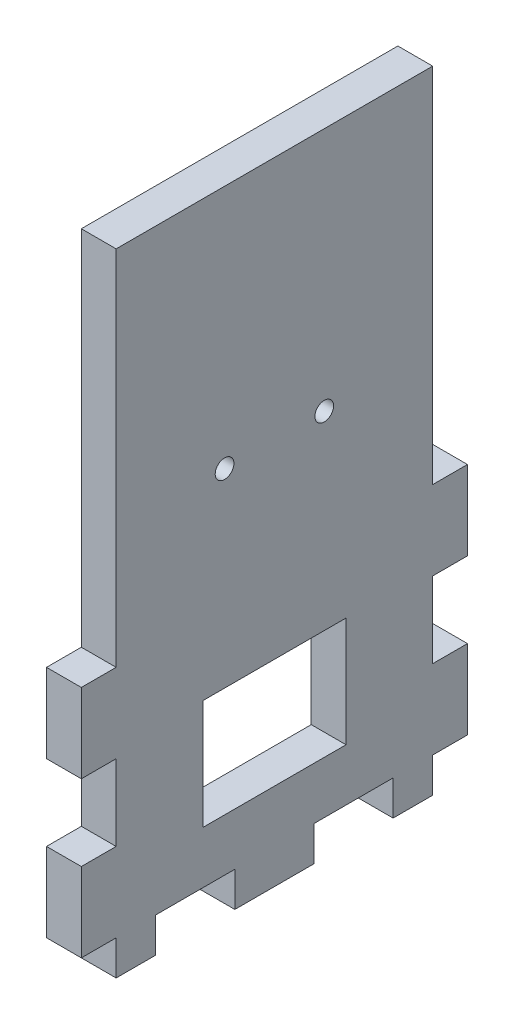
from build123d import *

# Parameters (mm, degrees)
SKETCH1_W              = 273.05
SKETCH1_H              = 139.7
BOSS_EXTRUDE1_DEPTH    = 5.588
SKETCH2_W              = 273.05
SKETCH2_H              = 139.7
SKETCH2_W_2            = 261.874
SKETCH2_H_2            = 128.524
BOSS_EXTRUDE2_DEPTH    = 298.45
SKETCH3_W              = 6.35
SKETCH3_H              = 16.933333333
SKETCH3_H_2            = 16.933333334
DOOR_SLOT_DEPTH        = 12.7
DOOR_GUIDE_HOLES_REACH = 361.255
SKETCH4_W              = 6.35
SKETCH4_H              = 15.875
LEVER_HOLES_W          = 9.652
LEVER_HOLES_H          = 6.35
LEVER_HOLES_W_2        = 6.35
CUT_EXTRUDE1_DEPTH     = 362.378293578
CUT_EXTRUDE3_REACH     = 416.577
SKETCH8_R              = 3.175
SKETCH16_W             = 327.238778096
SKETCH16_H             = 314.471565403
CUT_EXTRUDE10_DEPTH    = 362.378293578
LEFT_RIGHT_W           = 6.35
LEFT_RIGHT_H           = 5.588
LEFT_RIGHT_W_2         = 12.7
LEFT_RIGHT_H_2         = 12.66825
CUT_EXTRUDE11_DEPTH    = 415.577411883
SKETCH17_R             = 1.5
SKETCH17_W             = 23
SKETCH17_H             = 17.61800007
CUT_EXTRUDE12_DEPTH    = 313.00857951
CUT_EXTRUDE13_DEPTH    = 313.00857951


with BuildPart() as part:
    # Sketch1 → Boss-Extrude1 (new body)
    with BuildSketch(Plane(origin=(0, 0, 0), x_dir=(1, 0, 0), z_dir=(0, 1, 0))):
        Rectangle(SKETCH1_W, SKETCH1_H)
    extrude(amount=BOSS_EXTRUDE1_DEPTH)

    # Sketch2 → Boss-Extrude2 (add)
    with BuildSketch(Plane(origin=(0, 5.588, 0), x_dir=(1, 0, 0), z_dir=(0, 1, 0))):
        Rectangle(SKETCH2_W, SKETCH2_H)
        Rectangle(SKETCH2_W_2, SKETCH2_H_2, mode=Mode.SUBTRACT)
    extrude(amount=BOSS_EXTRUDE2_DEPTH)

    # Sketch3 → Door Slot (cut)
    with BuildSketch(Plane.XY.offset(69.85)):
        with BuildLine():
            Line((-29.337, 282.448), (-29.337, 5.588))
            Line((-29.337, 5.588), (-22.733, 5.588))
            Line((-22.733, 5.588), (-22.733, 291.592))
            Line((-22.733, 291.592), (-42.291, 291.592))
            Line((-42.291, 291.592), (-42.291, 284.988))
            Line((-42.291, 284.988), (-31.877, 284.988))
            ThreePointArc((-31.877, 284.988), (-30.080948776, 284.244051224), (-29.337, 282.448))
        make_face()
        with Locations((-13.208, 80.433333334)):
            Rectangle(SKETCH3_W, SKETCH3_H)
        with Locations((-13.208, 50.8)):
            Rectangle(SKETCH3_W, SKETCH3_H_2)
        with Locations((-13.208, 21.166666667)):
            Rectangle(SKETCH3_W, SKETCH3_H)
    extrude(amount=-DOOR_SLOT_DEPTH, mode=Mode.SUBTRACT)

    # Sketch4 → Door Guide Holes (cut, up to next)
    with BuildSketch(Plane.XY.offset(-64.262), mode=Mode.PRIVATE) as door_guide_holes_sk1:
        with Locations((-45.466, 283.4005)):
            Rectangle(SKETCH4_W, SKETCH4_H)
    door_guide_holes_tool1 = extrude(door_guide_holes_sk1.sketch, amount=-DOOR_GUIDE_HOLES_REACH, mode=Mode.PRIVATE) & part.part
    # Sketch4 → Door Guide Holes (cut, up to next)
    with BuildSketch(Plane.XY.offset(-64.262), mode=Mode.PRIVATE) as door_guide_holes_sk2:
        with Locations((-45.466, 254.8255)):
            Rectangle(SKETCH4_W, SKETCH4_H)
    door_guide_holes_tool2 = extrude(door_guide_holes_sk2.sketch, amount=-DOOR_GUIDE_HOLES_REACH, mode=Mode.PRIVATE) & part.part
    # Sketch4 → Door Guide Holes (cut, up to next)
    with BuildSketch(Plane.XY.offset(-64.262), mode=Mode.PRIVATE) as door_guide_holes_sk3:
        with Locations((-45.466, 226.2505)):
            Rectangle(SKETCH4_W, SKETCH4_H)
    door_guide_holes_tool3 = extrude(door_guide_holes_sk3.sketch, amount=-DOOR_GUIDE_HOLES_REACH, mode=Mode.PRIVATE) & part.part
    # Sketch4 → Door Guide Holes (cut, up to next)
    with BuildSketch(Plane.XY.offset(-64.262), mode=Mode.PRIVATE) as door_guide_holes_sk4:
        with Locations((-45.466, 197.6755)):
            Rectangle(SKETCH4_W, SKETCH4_H)
    door_guide_holes_tool4 = extrude(door_guide_holes_sk4.sketch, amount=-DOOR_GUIDE_HOLES_REACH, mode=Mode.PRIVATE) & part.part
    # Sketch4 → Door Guide Holes (cut, up to next)
    with BuildSketch(Plane.XY.offset(-64.262), mode=Mode.PRIVATE) as door_guide_holes_sk5:
        with Locations((-45.466, 169.1005)):
            Rectangle(SKETCH4_W, SKETCH4_H)
    door_guide_holes_tool5 = extrude(door_guide_holes_sk5.sketch, amount=-DOOR_GUIDE_HOLES_REACH, mode=Mode.PRIVATE) & part.part
    # Sketch4 → Door Guide Holes (cut, up to next)
    with BuildSketch(Plane.XY.offset(-64.262), mode=Mode.PRIVATE) as door_guide_holes_sk6:
        with Locations((-45.466, 140.5255)):
            Rectangle(SKETCH4_W, SKETCH4_H)
    door_guide_holes_tool6 = extrude(door_guide_holes_sk6.sketch, amount=-DOOR_GUIDE_HOLES_REACH, mode=Mode.PRIVATE) & part.part
    # Sketch4 → Door Guide Holes (cut, up to next)
    with BuildSketch(Plane.XY.offset(-64.262), mode=Mode.PRIVATE) as door_guide_holes_sk7:
        with Locations((-45.466, 111.9505)):
            Rectangle(SKETCH4_W, SKETCH4_H)
    door_guide_holes_tool7 = extrude(door_guide_holes_sk7.sketch, amount=-DOOR_GUIDE_HOLES_REACH, mode=Mode.PRIVATE) & part.part
    # Sketch4 → Door Guide Holes (cut, up to next)
    with BuildSketch(Plane.XY.offset(-64.262), mode=Mode.PRIVATE) as door_guide_holes_sk8:
        with Locations((-45.466, 83.3755)):
            Rectangle(SKETCH4_W, SKETCH4_H)
    door_guide_holes_tool8 = extrude(door_guide_holes_sk8.sketch, amount=-DOOR_GUIDE_HOLES_REACH, mode=Mode.PRIVATE) & part.part
    # Sketch4 → Door Guide Holes (cut, up to next)
    with BuildSketch(Plane.XY.offset(-64.262), mode=Mode.PRIVATE) as door_guide_holes_sk9:
        with Locations((-45.466, 54.8005)):
            Rectangle(SKETCH4_W, SKETCH4_H)
    door_guide_holes_tool9 = extrude(door_guide_holes_sk9.sketch, amount=-DOOR_GUIDE_HOLES_REACH, mode=Mode.PRIVATE) & part.part
    # Sketch4 → Door Guide Holes (cut, up to next)
    with BuildSketch(Plane.XY.offset(-64.262), mode=Mode.PRIVATE) as door_guide_holes_sk10:
        with Locations((-45.466, 26.2255)):
            Rectangle(SKETCH4_W, SKETCH4_H)
    door_guide_holes_tool10 = extrude(door_guide_holes_sk10.sketch, amount=-DOOR_GUIDE_HOLES_REACH, mode=Mode.PRIVATE) & part.part
    door_guide_holes_1 = door_guide_holes_tool1.solids().sort_by_distance((-45.466, 283.4005, -64.262))[0]
    add(door_guide_holes_1, mode=Mode.SUBTRACT)
    door_guide_holes_2 = door_guide_holes_tool2.solids().sort_by_distance((-45.466, 254.8255, -64.262))[0]
    add(door_guide_holes_2, mode=Mode.SUBTRACT)
    door_guide_holes_3 = door_guide_holes_tool3.solids().sort_by_distance((-45.466, 226.2505, -64.262))[0]
    add(door_guide_holes_3, mode=Mode.SUBTRACT)
    door_guide_holes_4 = door_guide_holes_tool4.solids().sort_by_distance((-45.466, 197.6755, -64.262))[0]
    add(door_guide_holes_4, mode=Mode.SUBTRACT)
    door_guide_holes_5 = door_guide_holes_tool5.solids().sort_by_distance((-45.466, 169.1005, -64.262))[0]
    add(door_guide_holes_5, mode=Mode.SUBTRACT)
    door_guide_holes_6 = door_guide_holes_tool6.solids().sort_by_distance((-45.466, 140.5255, -64.262))[0]
    add(door_guide_holes_6, mode=Mode.SUBTRACT)
    door_guide_holes_7 = door_guide_holes_tool7.solids().sort_by_distance((-45.466, 111.9505, -64.262))[0]
    add(door_guide_holes_7, mode=Mode.SUBTRACT)
    door_guide_holes_8 = door_guide_holes_tool8.solids().sort_by_distance((-45.466, 83.3755, -64.262))[0]
    add(door_guide_holes_8, mode=Mode.SUBTRACT)
    door_guide_holes_9 = door_guide_holes_tool9.solids().sort_by_distance((-45.466, 54.8005, -64.262))[0]
    add(door_guide_holes_9, mode=Mode.SUBTRACT)
    door_guide_holes_10 = door_guide_holes_tool10.solids().sort_by_distance((-45.466, 26.2255, -64.262))[0]
    add(door_guide_holes_10, mode=Mode.SUBTRACT)
    door_guide_holes = door_guide_holes_1 + door_guide_holes_2 + door_guide_holes_3 + door_guide_holes_4 + door_guide_holes_5 + door_guide_holes_6 + door_guide_holes_7 + door_guide_holes_8 + door_guide_holes_9 + door_guide_holes_10  # Door Guide Holes as one shape, for the pattern or mirror that repeats it

    # Mirror1: Door Guide Holes across plane
    add(door_guide_holes.mirror(Plane.ZY.offset(32.512)), mode=Mode.SUBTRACT)

    # Lever Holes → Cut-Extrude1 (cut, through all)
    with BuildSketch(Plane.XY.offset(69.85)):
        with Locations((54.102, 28.575)):
            Rectangle(LEVER_HOLES_W, LEVER_HOLES_H)
        with Locations((39.3065, 15.875)):
            Rectangle(LEVER_HOLES_W_2, LEVER_HOLES_H)
        with Locations((68.8975, 15.875)):
            Rectangle(LEVER_HOLES_W_2, LEVER_HOLES_H)
    extrude(amount=-CUT_EXTRUDE1_DEPTH, mode=Mode.SUBTRACT)

    # Sketch8 → Cut-Extrude3 (cut, up to next)
    with BuildSketch(Plane.ZY.offset(136.525), mode=Mode.PRIVATE) as cut_extrude3_sk1:
        with Locations((0, 19.05)):
            Circle(SKETCH8_R)
    cut_extrude3_tool1 = extrude(cut_extrude3_sk1.sketch, amount=-CUT_EXTRUDE3_REACH, mode=Mode.PRIVATE) & part.part
    add(cut_extrude3_tool1.solids().sort_by_distance((-136.525, 19.05, 0))[0], mode=Mode.SUBTRACT)

    # Sketch16 → Cut-Extrude10 (cut, through all)
    with BuildSketch(Plane.XY.offset(69.85)):
        with Locations((-32.682389048, 146.802217299)):
            Rectangle(SKETCH16_W, SKETCH16_H)
    extrude(amount=-CUT_EXTRUDE10_DEPTH, mode=Mode.SUBTRACT)

    # Left/Right → Cut-Extrude11 (cut, through all)
    with BuildSketch(Plane.ZY.offset(136.525)):
        with Locations((60.325, 2.794)):
            Rectangle(LEFT_RIGHT_W, LEFT_RIGHT_H)
        with Locations((38.1, 2.794)):
            Rectangle(LEFT_RIGHT_W_2, LEFT_RIGHT_H)
        with Locations((66.675, 19.002375)):
            Rectangle(LEFT_RIGHT_W, LEFT_RIGHT_H_2)
        with Locations((12.7, 2.794)):
            Rectangle(LEFT_RIGHT_W_2, LEFT_RIGHT_H)
        with Locations((66.675, 44.338875)):
            Rectangle(LEFT_RIGHT_W, LEFT_RIGHT_H_2)
        with Locations((-12.7, 2.794)):
            Rectangle(LEFT_RIGHT_W_2, LEFT_RIGHT_H)
        with Locations((66.675, 69.675375)):
            Rectangle(LEFT_RIGHT_W, LEFT_RIGHT_H_2)
        with Locations((-38.1, 2.794)):
            Rectangle(LEFT_RIGHT_W_2, LEFT_RIGHT_H)
        with Locations((66.675, 95.011875)):
            Rectangle(LEFT_RIGHT_W, LEFT_RIGHT_H_2)
        with Locations((-60.325, 2.794)):
            Rectangle(LEFT_RIGHT_W, LEFT_RIGHT_H)
        with Locations((66.675, 120.348375)):
            Rectangle(LEFT_RIGHT_W, LEFT_RIGHT_H_2)
        with Locations((-66.675, 19.002375)):
            Rectangle(LEFT_RIGHT_W, LEFT_RIGHT_H_2)
        with Locations((66.675, 145.684875)):
            Rectangle(LEFT_RIGHT_W, LEFT_RIGHT_H_2)
        with Locations((-66.675, 44.338875)):
            Rectangle(LEFT_RIGHT_W, LEFT_RIGHT_H_2)
        with Locations((66.675, 171.021375)):
            Rectangle(LEFT_RIGHT_W, LEFT_RIGHT_H_2)
        with Locations((-66.675, 69.675375)):
            Rectangle(LEFT_RIGHT_W, LEFT_RIGHT_H_2)
        with Locations((66.675, 196.357875)):
            Rectangle(LEFT_RIGHT_W, LEFT_RIGHT_H_2)
        with Locations((-66.675, 95.011875)):
            Rectangle(LEFT_RIGHT_W, LEFT_RIGHT_H_2)
        with Locations((66.675, 221.694375)):
            Rectangle(LEFT_RIGHT_W, LEFT_RIGHT_H_2)
        with Locations((-66.675, 120.348375)):
            Rectangle(LEFT_RIGHT_W, LEFT_RIGHT_H_2)
        with Locations((66.675, 247.030875)):
            Rectangle(LEFT_RIGHT_W, LEFT_RIGHT_H_2)
        with Locations((-66.675, 145.684875)):
            Rectangle(LEFT_RIGHT_W, LEFT_RIGHT_H_2)
        with Locations((66.675, 272.367375)):
            Rectangle(LEFT_RIGHT_W, LEFT_RIGHT_H_2)
        with Locations((-66.675, 171.021375)):
            Rectangle(LEFT_RIGHT_W, LEFT_RIGHT_H_2)
        with Locations((66.675, 297.703875)):
            Rectangle(LEFT_RIGHT_W, LEFT_RIGHT_H_2)
        with Locations((-66.675, 196.357875)):
            Rectangle(LEFT_RIGHT_W, LEFT_RIGHT_H_2)
        with Locations((-66.675, 221.694375)):
            Rectangle(LEFT_RIGHT_W, LEFT_RIGHT_H_2)
        with Locations((-66.675, 247.030875)):
            Rectangle(LEFT_RIGHT_W, LEFT_RIGHT_H_2)
        with Locations((-66.675, 272.367375)):
            Rectangle(LEFT_RIGHT_W, LEFT_RIGHT_H_2)
        with Locations((-66.675, 297.703875)):
            Rectangle(LEFT_RIGHT_W, LEFT_RIGHT_H_2)
    extrude(amount=-CUT_EXTRUDE11_DEPTH, mode=Mode.SUBTRACT)

    # Sketch17 → Cut-Extrude12 (cut, through all)
    with BuildSketch(Plane(origin=(136.525, 0, 0), x_dir=(0, 0, -1), z_dir=(1, 0, 0))):
        with Locations((-8, 62.088)):
            Circle(SKETCH17_R)
        with Locations((8, 62.088)):
            Circle(SKETCH17_R)
        with Locations((-50.8, 159.894)):
            Circle(SKETCH17_R)
        with Locations((-50.8, 144.144)):
            Circle(SKETCH17_R)
        with Locations(Location((50.8, 144.144, 0), (0, 0, 180))):
            Circle(SKETCH17_R)
        with Locations(Location((50.8, 159.894, 0), (0, 0, 180))):
            Circle(SKETCH17_R)
        with Locations((0, 22.779000035)):
            Rectangle(SKETCH17_W, SKETCH17_H)
    extrude(amount=-CUT_EXTRUDE12_DEPTH, mode=Mode.SUBTRACT)

    # Sketch18 → Cut-Extrude13 (cut, through all)
    with BuildSketch(Plane(origin=(136.525, 0, 0), x_dir=(0, 0, -1), z_dir=(1, 0, 0))):
        Polygon((-69.85, 304.038), (-69.85, 0), (-25.4, 0), (-25.4, 5.588), (-30.988, 5.588), (-30.988, 18.288), (-25.4, 18.288), (-25.4, 30.48), (-30.988, 30.48), (-30.988, 43.18), (-25.4, 43.18), (-25.4, 101.346), (25.4, 101.346), (25.4, 43.18), (30.988, 43.18), (30.988, 30.48), (25.4, 30.48), (25.4, 18.288), (30.988, 18.288), (30.988, 5.588), (25.4, 5.588), (25.4, 0), (69.85, 0), (69.85, 304.038), align=None)
    extrude(amount=-CUT_EXTRUDE13_DEPTH, mode=Mode.SUBTRACT)


solid = part.part
